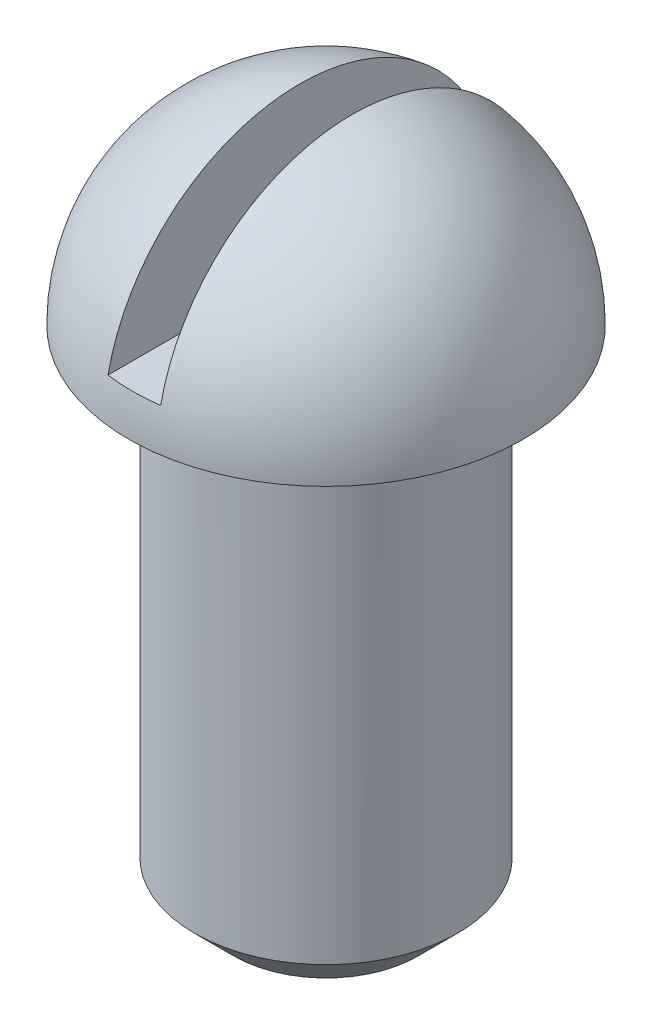
from build123d import *

# Parameters (mm, degrees)
SKETCH6_W          = 4
SKETCH6_H          = 15
CUT_EXTRUDE1_DEPTH = 27.5
CHAMFER1_SIZE      = 3


with BuildPart() as part:
    # Sketch4 → Revolve1 (revolve)
    with BuildSketch(Plane.XY):
        with BuildLine():
            Line((0, 0), (10, 0))
            Line((10, 0), (10, 53))
            ThreePointArc((10, 53), (-0.606601718, 48.606601718), (-5, 38))
            Line((-5, 38), (0, 38))
            Line((0, 38), (0, 0))
        make_face()
    revolve(axis=Axis((10, -13.659497016, 0), (0, 1, 0)))

    # Sketch6 → Cut-Extrude1 (cut, symmetric)
    with BuildSketch(Plane.XY):
        with Locations((10, 48.5)):
            Rectangle(SKETCH6_W, SKETCH6_H)
    extrude(amount=CUT_EXTRUDE1_DEPTH, both=True, mode=Mode.SUBTRACT)

    # Chamfer1
    chamfer1_edges = [part.edges().sort_by_distance(p)[0] for p in [
        (20, 0, 0),
    ]]
    chamfer(chamfer1_edges, length=CHAMFER1_SIZE)


solid = part.part
